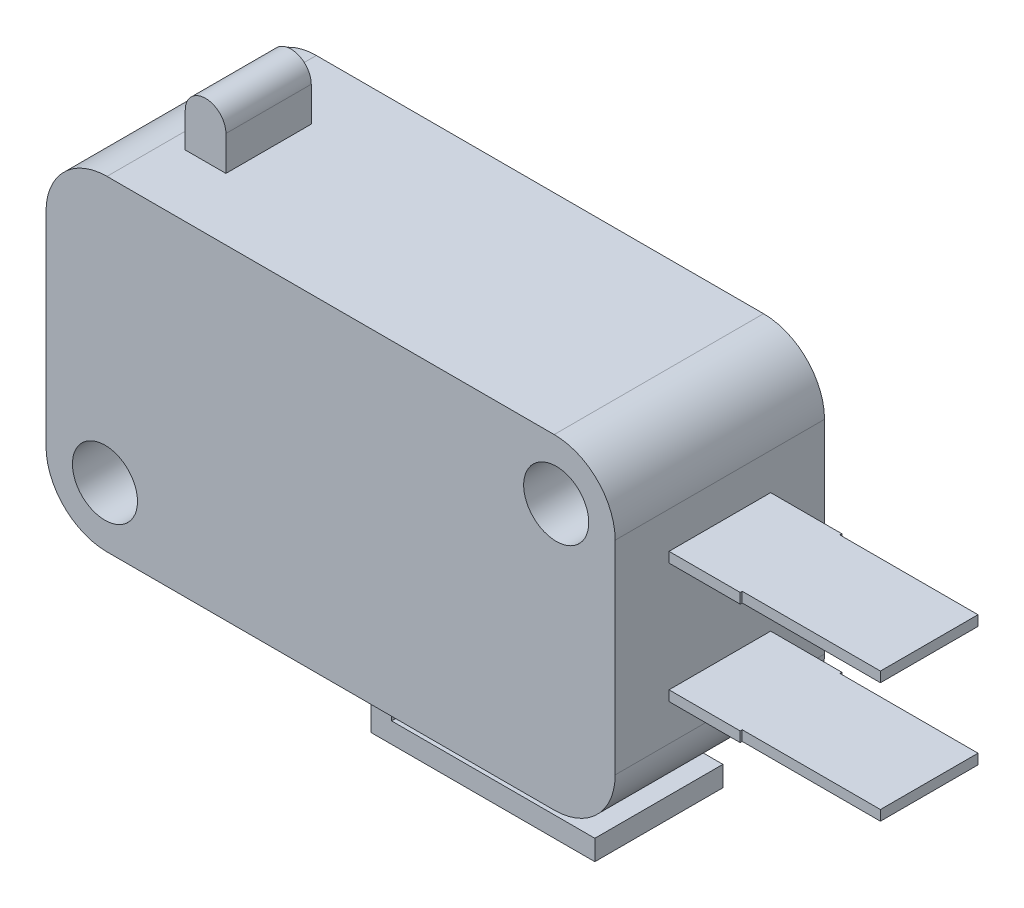
from build123d import *

# Parameters (mm, degrees)
SKETCH_1_W          = 28
SKETCH_1_H          = 10.3
EXTRUDE_1_DEPTH     = 16
SKETCH_2_R          = 1.6
CUT_EXTRUDE_1_DEPTH = 16
FILLET_1_R          = 3
EXTRUDE_START       = -3.05
EXTRUDE_2_DEPTH     = 4.2
SKETCH_4_W          = 5
SKETCH_4_H          = 0.5
EXTRUDE_3_DEPTH     = 10.3
SKETCH_5_W          = 6.8
SKETCH_5_H          = 0.1
CUT_EXTRUDE_2_DEPTH = 42.211891488
EXTRUDE_START_2     = -2
EXTRUDE_4_DEPTH     = 6.3


with BuildPart() as part:
    # 草图1 → 凸台-拉伸1 (new body)
    with BuildSketch(Plane(origin=(0, 0, 0), x_dir=(1, 0, 0), z_dir=(0, 1, 0))):
        with Locations((14, 5.15)):
            Rectangle(SKETCH_1_W, SKETCH_1_H)
    extrude(amount=EXTRUDE_1_DEPTH)

    # 草图2 → 切除-拉伸1 (cut)
    with BuildSketch(Plane.XY):
        with Locations((2.9, 2.9)):
            Circle(SKETCH_2_R)
        with Locations((25.1, 13.1)):
            Circle(SKETCH_2_R)
    extrude(amount=-CUT_EXTRUDE_1_DEPTH, mode=Mode.SUBTRACT)

    # 圆角1
    fillet_1_edges = [part.edges().sort_by_distance(p)[0] for p in [
        (28, 0, -5.15),
        (0, 0, -5.15),
        (28, 16, -5.15),
        (0, 16, -5.15),
    ]]
    fillet(fillet_1_edges, radius=FILLET_1_R)

    # 草图3 → 凸台-拉伸2 (add)
    with BuildSketch(Plane.XY.offset(EXTRUDE_START)):
        with BuildLine():
            Line((3.8, 16), (3.8, 17.7))
            ThreePointArc((3.8, 17.7), (4.8, 18.7), (5.8, 17.7))
            Line((5.8, 17.7), (5.8, 16))
            Line((5.8, 16), (3.8, 16))
        make_face()
    extrude(amount=-EXTRUDE_2_DEPTH)

    # 草图4 → 凸台-拉伸3 (add)
    with BuildSketch(Plane(origin=(28, 0, 0), x_dir=(0, 0, -1), z_dir=(1, 0, 0))):
        with Locations((5.15, 10.95)):
            Rectangle(SKETCH_4_W, SKETCH_4_H)
        with Locations((5.15, 5.05)):
            Rectangle(SKETCH_4_W, SKETCH_4_H)
    extrude(amount=EXTRUDE_3_DEPTH)

    # 草图5 → 切除-拉伸2 (cut, through all)
    with BuildSketch(Plane(origin=(0, 11.2, 0), x_dir=(1, 0, 0), z_dir=(0, 1, 0))):
        with Locations((34.9, 7.6)):
            Rectangle(SKETCH_5_W, SKETCH_5_H)
        with Locations((34.9, 2.7)):
            Rectangle(SKETCH_5_W, SKETCH_5_H)
    extrude(amount=-CUT_EXTRUDE_2_DEPTH, mode=Mode.SUBTRACT)

    # 草图6 → 凸台-拉伸4 (add)
    with BuildSketch(Plane.XY.offset(EXTRUDE_START_2)):
        Polygon((14, 0), (14, -3.2), (25, -3.2), (25, -2.2), (15, -2.2), (15, 0), align=None)
    extrude(amount=-EXTRUDE_4_DEPTH)


solid = part.part
